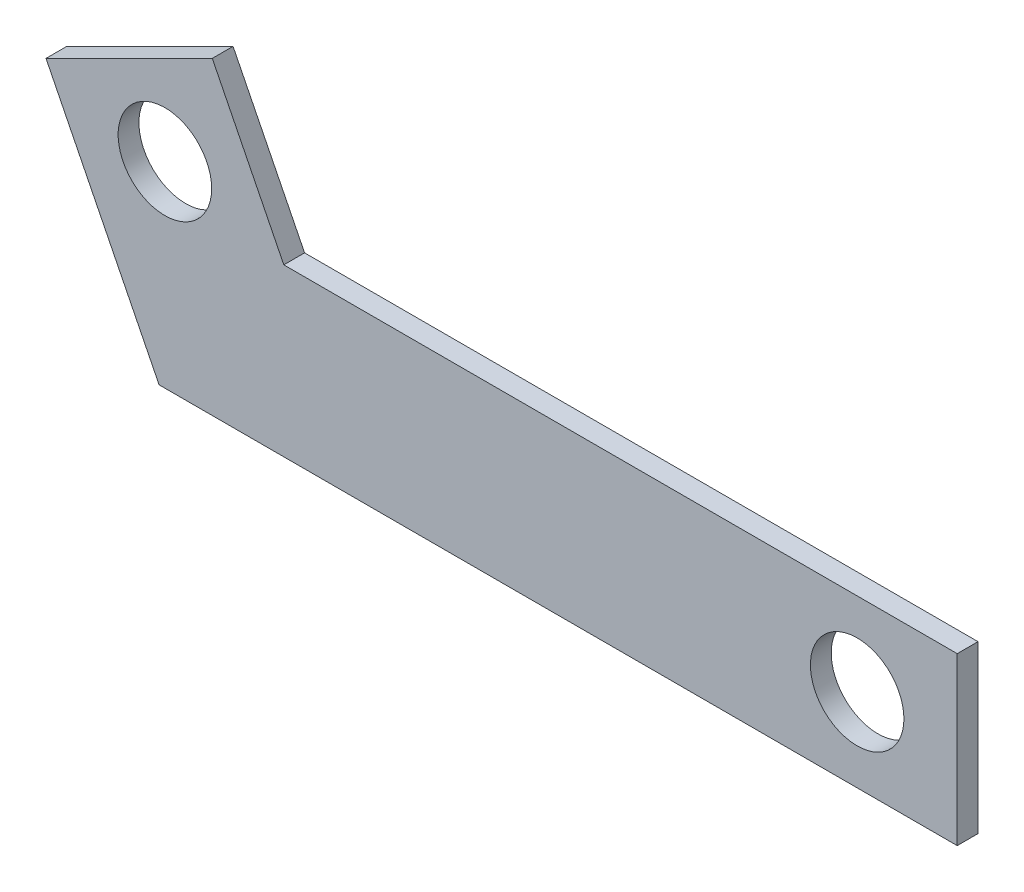
from build123d import *

# Parameters (mm, degrees)
BOSS_EXTRUDE1_DEPTH = 6.35
SKETCH3_R           = 14.2875
CUT_EXTRUDE1_DEPTH  = 6.35


with BuildPart() as part:
    # Sketch2 → Boss-Extrude1 (new body)
    with BuildSketch(Plane.XY):
        Polygon((-139.782733066, 36.902663481), (-174.336149065, 106.009480913), (-123.536149065, 131.409486267), (-101.682733066, 87.702663481), (104.057266934, 87.702663481), (104.057266934, 36.902663481), align=None)
    extrude(amount=BOSS_EXTRUDE1_DEPTH)

    # Sketch3 → Cut-Extrude1 (cut)
    with BuildSketch(Plane.XY.offset(6.35)):
        with Locations((73.490307261, 62.302663481)):
            Circle(SKETCH3_R)
        with Locations((-138.009441066, 96.856072197)):
            Circle(SKETCH3_R)
    extrude(amount=-CUT_EXTRUDE1_DEPTH, mode=Mode.SUBTRACT)


solid = part.part
